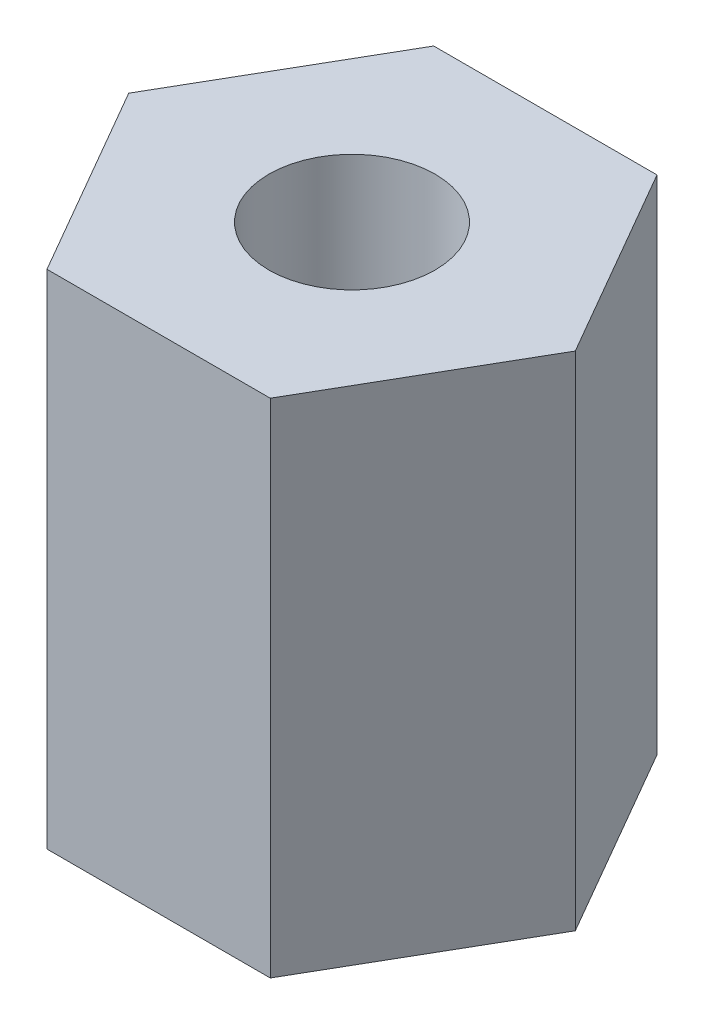
from build123d import *

# Parameters (mm, degrees)
BOSS_EXTRUDE1_DEPTH = 6.6
SKETCH2_R           = 1.0922
CUT_EXTRUDE1_DEPTH  = 6.6


with BuildPart() as part:
    # Sketch1 → Boss-Extrude1 (new body)
    with BuildSketch(Plane(origin=(0, 0, 0), x_dir=(1, 0, 0), z_dir=(0, 1, 0))):
        Polygon((-1.4675, 2.54178456), (-2.935, 0), (-1.4675, -2.54178456), (1.4675, -2.54178456), (2.935, 0), (1.4675, 2.54178456), align=None)
    extrude(amount=BOSS_EXTRUDE1_DEPTH)

    # Sketch2 → Cut-Extrude1 (cut)
    with BuildSketch(Plane(origin=(0, 0, 0), x_dir=(-1, 0, 0), z_dir=(0, -1, 0))):
        Circle(SKETCH2_R)
    extrude(amount=-CUT_EXTRUDE1_DEPTH, mode=Mode.SUBTRACT)


solid = part.part
